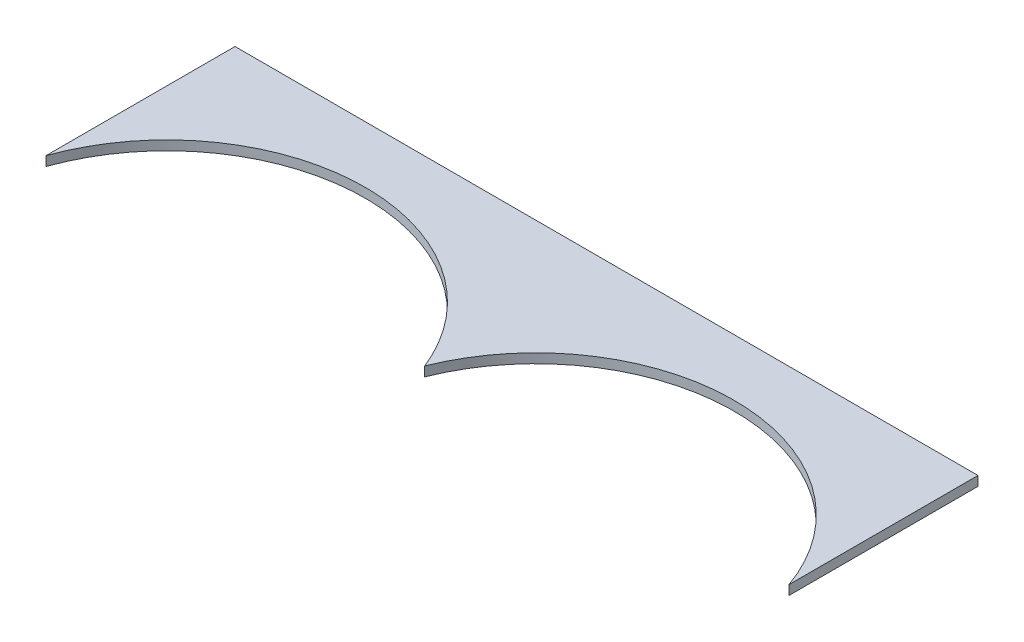
from build123d import *

# Parameters (mm, degrees)
BOSS_EXTRU_1_DEPTH = 2


with BuildPart() as part:
    # Esquisse1 → Boss.-Extru.1 (new body)
    with BuildSketch(Plane(origin=(0, 0, 0), x_dir=(1, 0, 0), z_dir=(0, 1, 0))):
        with BuildLine():
            Line((-72.21150364, 21.327505301), (85.019264112, 21.327505301))
            Line((85.019264112, 21.327505301), (85.019264112, -18.672494699))
            ThreePointArc((85.019264112, -18.672494699), (46.232543926, 9.298568327), (6.403880236, -17.167779708))
            ThreePointArc((6.403880236, -17.167779708), (-33.424783453, 9.298568327), (-72.21150364, -18.672494699))
            Line((-72.21150364, -18.672494699), (-72.21150364, 21.327505301))
        make_face()
    extrude(amount=BOSS_EXTRU_1_DEPTH)


solid = part.part
